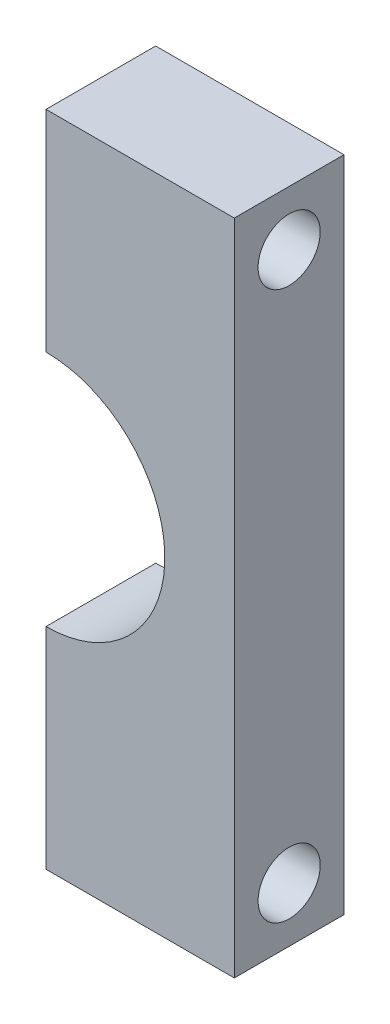
from build123d import *

# Parameters (mm, degrees)
BOSS_EXTRUDE1_DEPTH = 30
SKETCH2_R           = 8.5
CUT_EXTRUDE1_DEPTH  = 52.5
LPATTERN1_COUNT     = 2
LPATTERN1_PITCH     = 150
SKETCH3_R           = 4.75
CUT_EXTRUDE2_DEPTH  = 15
LPATTERN2_COUNT     = 2
LPATTERN2_PITCH     = 83


with BuildPart() as part:
    # Sketch1 → Boss-Extrude1 (new body)
    with BuildSketch(Plane.XY):
        with BuildLine():
            Line((0, 122.5), (0, 180))
            Line((0, 180), (51.5, 180))
            Line((51.5, 180), (51.5, 0))
            Line((51.5, 0), (0, 0))
            Line((0, 0), (0, 57.5))
            ThreePointArc((0, 57.5), (32.5, 90), (0, 122.5))
        make_face()
    extrude(amount=BOSS_EXTRUDE1_DEPTH)

    # Sketch2 → Cut-Extrude1 (cut, through all)
    with BuildSketch(Plane.ZY):
        with Locations((15, 15)):
            Circle(SKETCH2_R)
    cut_extrude1 = extrude(amount=-CUT_EXTRUDE1_DEPTH, mode=Mode.SUBTRACT)

    # LPattern1: Cut-Extrude1 ×2
    with Locations(*[(0, i * LPATTERN1_PITCH, 0) for i in range(1, LPATTERN1_COUNT)]):
        add(cut_extrude1, mode=Mode.SUBTRACT)

    # Sketch3 → Cut-Extrude2 (cut)
    with BuildSketch(Plane.ZY):
        with Locations((15, 48.5)):
            Circle(SKETCH3_R)
    cut_extrude2 = extrude(amount=-CUT_EXTRUDE2_DEPTH, mode=Mode.SUBTRACT)

    # LPattern2: Cut-Extrude2 ×2
    with Locations(*[(0, i * LPATTERN2_PITCH, 0) for i in range(1, LPATTERN2_COUNT)]):
        add(cut_extrude2, mode=Mode.SUBTRACT)


solid = part.part
